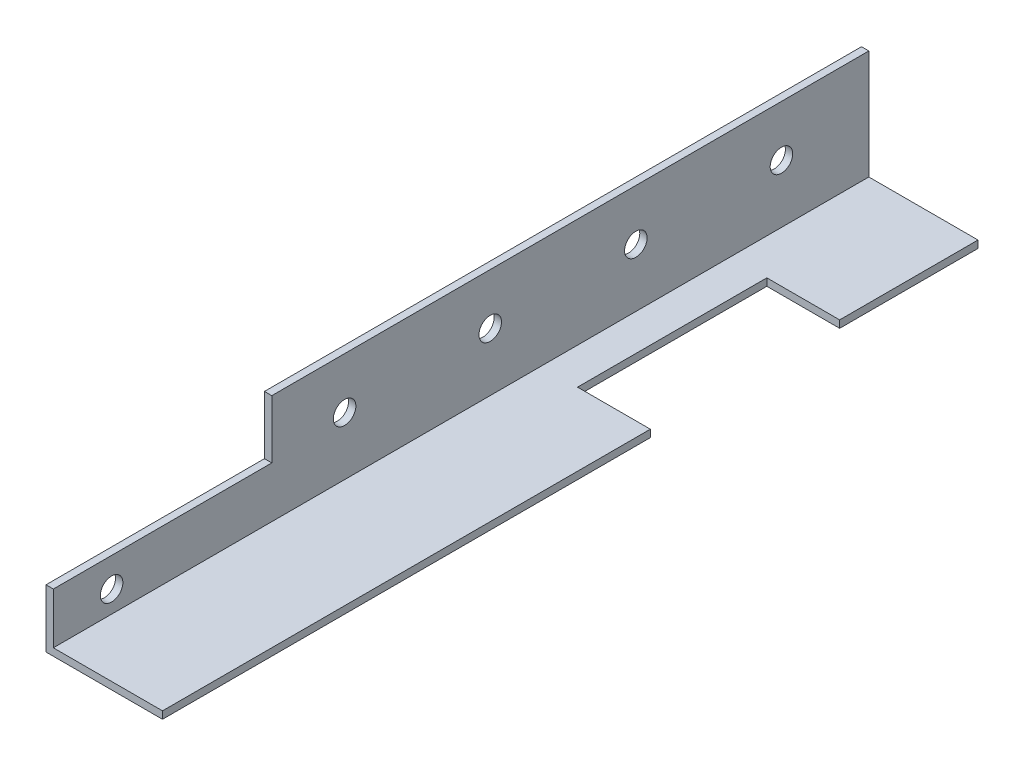
from build123d import *

# Parameters (mm, degrees)
BOSS_EXTRUDE1_DEPTH          = 177.8
F_10_0_1935_DIAMETER_HOLE1_D = 4.9149
SKETCH4_W                    = 15.875
SKETCH4_H                    = 41.275
CUT_EXTRUDE1_DEPTH           = 2.6002
SKETCH5_W                    = 47.625
SKETCH5_H                    = 12.7
CUT_EXTRUDE2_DEPTH           = 2.6002
F_10_0_1935_DIAMETER_HOLE2_D = 4.9149


with BuildPart() as part:
    # Sketch1 → Boss-Extrude1 (new body)
    with BuildSketch(Plane.XY):
        Polygon((0, 0), (0, 25.4), (1.6002, 25.4), (1.6002, 1.6002), (25.4, 1.6002), (25.4, 0), align=None)
    extrude(amount=BOSS_EXTRUDE1_DEPTH)

    # #10 (0.1935) Diameter Hole1 (through all)
    with Locations(Plane(origin=(1.6002, 0, 0), x_dir=(0, 0, -1), z_dir=(1, 0, 0))):
        with Locations((-82.55, 14.2875), (-50.8, 14.2875), (-19.05, 14.2875), (-114.3, 14.2875)):
            Hole(F_10_0_1935_DIAMETER_HOLE1_D / 2)

    # Sketch4 → Cut-Extrude1 (cut, through all)
    with BuildSketch(Plane(origin=(0, 1.6002, 0), x_dir=(1, 0, 0), z_dir=(0, 1, 0))):
        with Locations((17.4625, -50.8)):
            Rectangle(SKETCH4_W, SKETCH4_H)
    extrude(amount=-CUT_EXTRUDE1_DEPTH, mode=Mode.SUBTRACT)

    # Sketch5 → Cut-Extrude2 (cut, through all)
    with BuildSketch(Plane(origin=(1.6002, 0, 0), x_dir=(0, 0, -1), z_dir=(1, 0, 0))):
        with Locations((-153.9875, 19.05)):
            Rectangle(SKETCH5_W, SKETCH5_H)
    extrude(amount=-CUT_EXTRUDE2_DEPTH, mode=Mode.SUBTRACT)

    # #10 (0.1935) Diameter Hole2 (through all)
    with Locations(Plane(origin=(1.6002, 0, 0), x_dir=(0, 0, -1), z_dir=(1, 0, 0))):
        with Locations((-165.1, 6.35)):
            Hole(F_10_0_1935_DIAMETER_HOLE2_D / 2)


solid = part.part
